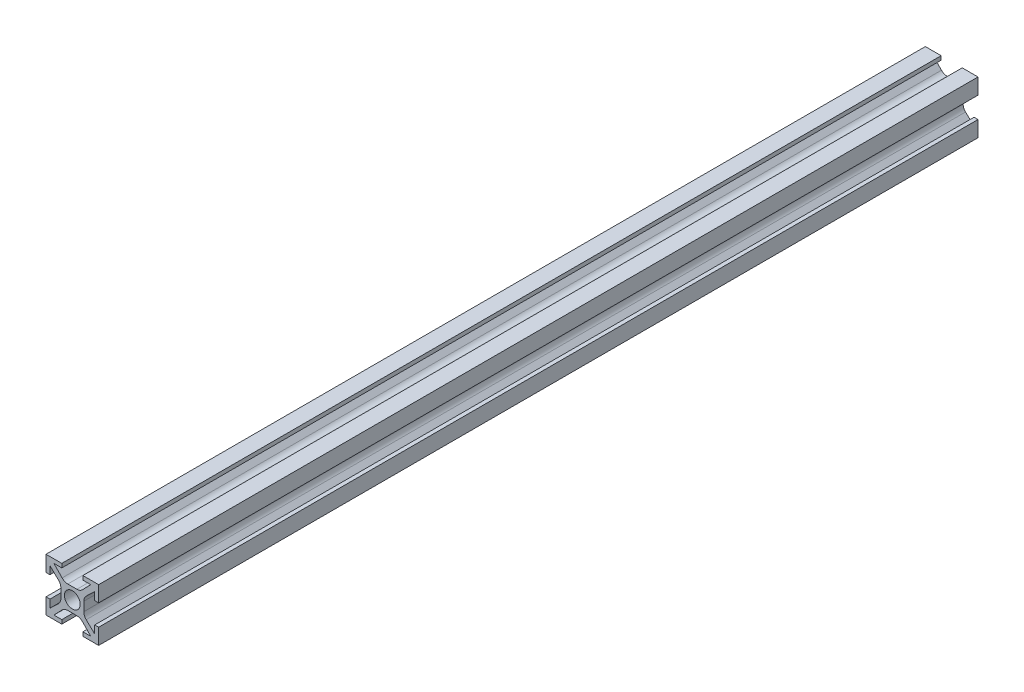
from build123d import *

# Parameters (mm, degrees)
ESBO_O1_W                  = 20
ESBO_O1_H                  = 20
RESSALTO_EXTRUS_O1_DEPTH   = 334
ESBO_O2_R                  = 3
CORTE_EXTRUS_O1_DEPTH      = 1
CORTE_EXTRUS_O1_DEPTH_BACK = 335
FILETE1_R                  = 3


with BuildPart() as part:
    # Esboço1 → Ressalto-extrusão1 (new body)
    with BuildSketch(Plane.XY):
        Rectangle(ESBO_O1_W, ESBO_O1_H)
    extrude(amount=RESSALTO_EXTRUS_O1_DEPTH)

    # Esboço2 → Corte-extrusão1 (cut, two sides)
    with BuildSketch(Plane(origin=(0, 0, 0), x_dir=(-1, 0, 0), z_dir=(0, 0, -1))) as corte_extrus_o1_sk:
        Circle(ESBO_O2_R)
        Polygon((-10, 4), (-8.5, 4), (-8.5, 7), (-4.353828188, 3), (-4.353828188, -3), (-8.5, -7), (-8.5, -4), (-10, -4), align=None)
        Polygon((4, 10), (4, 8.5), (7, 8.5), (3, 4.353828188), (-3, 4.353828188), (-7, 8.5), (-4, 8.5), (-4, 10), align=None)
        Polygon((10, -4), (8.5, -4), (8.5, -7), (4.353828188, -3), (4.353828188, 3), (8.5, 7), (8.5, 4), (10, 4), align=None)
        Polygon((-4, -10), (-4, -8.5), (-7, -8.5), (-3, -4.353828188), (3, -4.353828188), (7, -8.5), (4, -8.5), (4, -10), align=None)
    extrude(amount=CORTE_EXTRUS_O1_DEPTH, mode=Mode.SUBTRACT)
    extrude(corte_extrus_o1_sk.sketch, amount=-CORTE_EXTRUS_O1_DEPTH_BACK, mode=Mode.SUBTRACT)

    # Filete1
    filete1_edges = [part.edges().sort_by_distance(p)[0] for p in [
        (-3, 4.353828188, 167),
        (3, 4.353828188, 167),
        (4.353828188, 3, 167),
        (4.353828188, -3, 167),
        (3, -4.353828188, 167),
        (-3, -4.353828188, 167),
        (-4.353828188, -3, 167),
        (-4.353828188, 3, 167),
    ]]
    fillet(filete1_edges, radius=FILETE1_R)


solid = part.part
